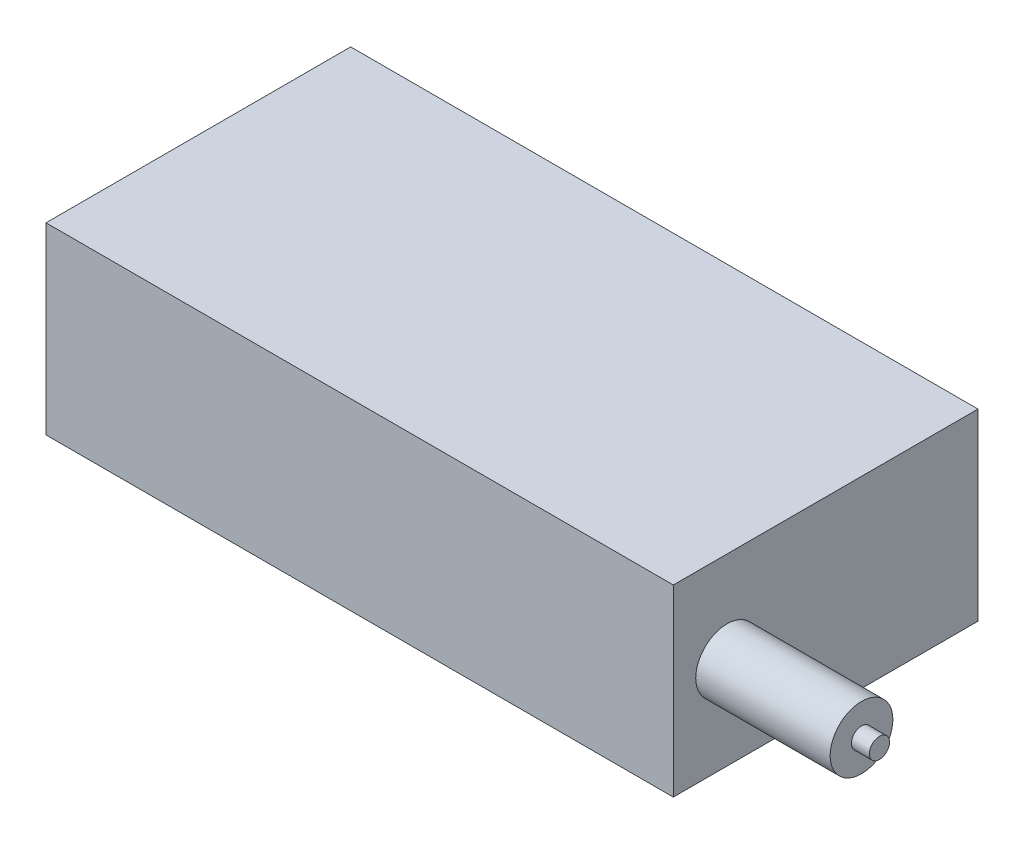
from build123d import *

# Parameters (mm, degrees)
SKETCH1_W           = 111.125
SKETCH1_H           = 53.975
BOSS_EXTRUDE1_DEPTH = 32.54375
SKETCH2_W           = 27.78125
SKETCH2_H           = 19.05
CUT_EXTRUDE1_DEPTH  = 3.175
SKETCH4_R           = 5.55625
BOSS_EXTRUDE2_DEPTH = 23.8125
SKETCH5_R           = 1.7859375
BOSS_EXTRUDE3_DEPTH = 3.175


with BuildPart() as part:
    # Sketch1 → Boss-Extrude1 (new body)
    with BuildSketch(Plane(origin=(0, 0, 0), x_dir=(1, 0, 0), z_dir=(0, 1, 0))):
        with Locations((55.5625, 26.9875)):
            Rectangle(SKETCH1_W, SKETCH1_H)
    extrude(amount=BOSS_EXTRUDE1_DEPTH)

    # Sketch2 → Cut-Extrude1 (cut)
    with BuildSketch(Plane.ZY):
        with Locations((-32.146875, 15.875)):
            Rectangle(SKETCH2_W, SKETCH2_H)
    extrude(amount=-CUT_EXTRUDE1_DEPTH, mode=Mode.SUBTRACT)

    # Sketch4 → Boss-Extrude2 (add)
    with BuildSketch(Plane(origin=(111.125, 0, 0), x_dir=(0, 0, -1), z_dir=(1, 0, 0))):
        with Locations((9.525, 16.271875)):
            Circle(SKETCH4_R)
    extrude(amount=BOSS_EXTRUDE2_DEPTH)

    # Sketch5 → Boss-Extrude3 (add)
    with BuildSketch(Plane(origin=(134.9375, 0, 0), x_dir=(0, 0, -1), z_dir=(1, 0, 0))):
        with Locations((9.525, 16.271875)):
            Circle(SKETCH5_R)
    extrude(amount=BOSS_EXTRUDE3_DEPTH)


solid = part.part
